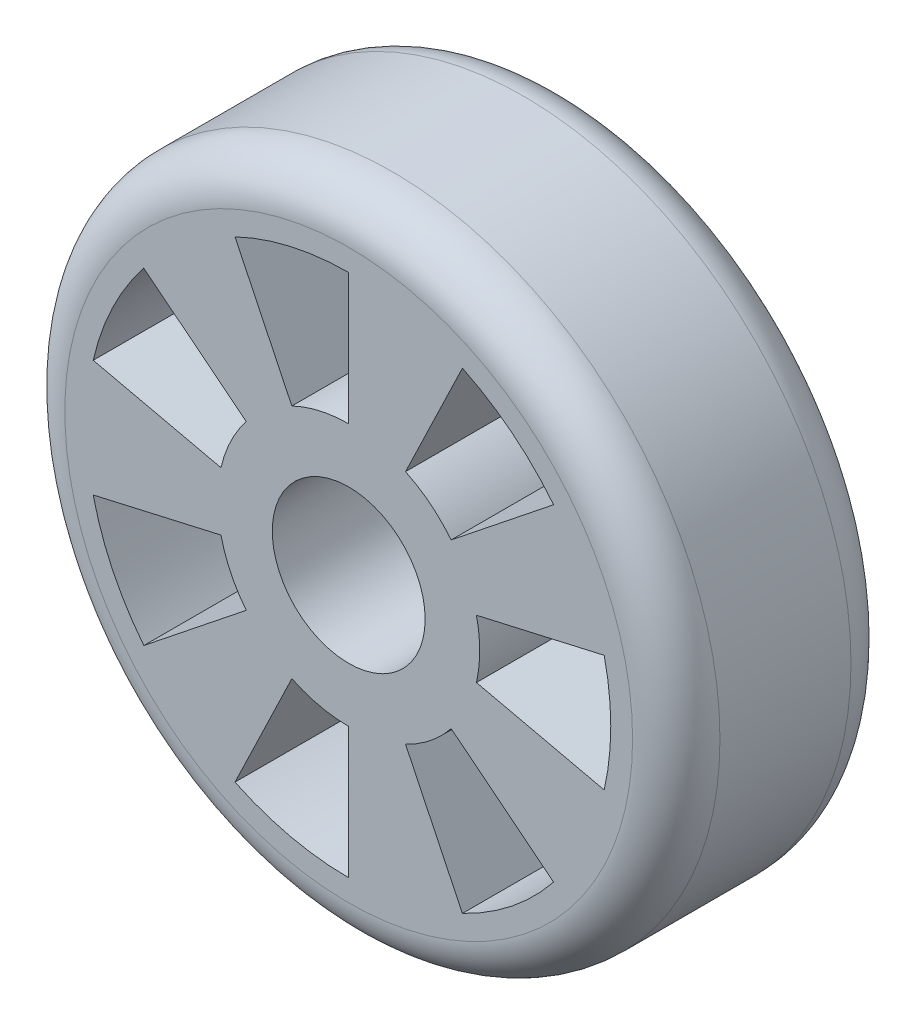
from build123d import *

# Parameters (mm, degrees)
SKETCH1_R           = 75
BOSS_EXTRUDE1_DEPTH = 50
FILLET1_R           = 10
SKETCH4_R           = 17.5
CUT_EXTRUDE1_DEPTH  = 51.0000001


with BuildPart() as part:
    # Sketch1 → Boss-Extrude1 (new body)
    with BuildSketch(Plane.XY):
        Circle(SKETCH1_R)
        with BuildLine():
            Line((0, 30), (0, 60))
            ThreePointArc((0, 60), (-13.351256037, 58.495674731), (-26.033024347, 54.058132074))
            Line((-26.033024347, 54.058132074), (-13.016512174, 27.029066037))
            ThreePointArc((-13.016512174, 27.029066037), (-6.675628019, 29.247837365), (0, 30))
        make_face(mode=Mode.SUBTRACT)
        with BuildLine():
            Line((13.016512174, 27.029066037), (26.033024347, 54.058132074))
            ThreePointArc((26.033024347, 54.058132074), (37.409388112, 46.909888948), (46.909888948, 37.409388112))
            Line((46.909888948, 37.409388112), (23.454944474, 18.704694056))
            ThreePointArc((23.454944474, 18.704694056), (18.704694056, 23.454944474), (13.016512174, 27.029066037))
        make_face(mode=Mode.SUBTRACT)
        with BuildLine():
            Line((29.247837365, 6.675628019), (58.495674731, 13.351256037))
            ThreePointArc((58.495674731, 13.351256037), (60, 0), (58.495674731, -13.351256037))
            Line((58.495674731, -13.351256037), (29.247837365, -6.675628019))
            ThreePointArc((29.247837365, -6.675628019), (30, 0), (29.247837365, 6.675628019))
        make_face(mode=Mode.SUBTRACT)
        with BuildLine():
            Line((23.454944474, -18.704694056), (46.909888948, -37.409388112))
            ThreePointArc((46.909888948, -37.409388112), (37.409388112, -46.909888948), (26.033024347, -54.058132074))
            Line((26.033024347, -54.058132074), (13.016512174, -27.029066037))
            ThreePointArc((13.016512174, -27.029066037), (18.704694056, -23.454944474), (23.454944474, -18.704694056))
        make_face(mode=Mode.SUBTRACT)
        with BuildLine():
            Line((0, -30), (0, -60))
            ThreePointArc((0, -60), (-13.351256037, -58.495674731), (-26.033024347, -54.058132074))
            Line((-26.033024347, -54.058132074), (-13.016512174, -27.029066037))
            ThreePointArc((-13.016512174, -27.029066037), (-6.675628019, -29.247837365), (0, -30))
        make_face(mode=Mode.SUBTRACT)
        with BuildLine():
            Line((-23.454944474, -18.704694056), (-46.909888948, -37.409388112))
            ThreePointArc((-46.909888948, -37.409388112), (-54.058132074, -26.033024347), (-58.495674731, -13.351256037))
            Line((-58.495674731, -13.351256037), (-29.247837365, -6.675628019))
            ThreePointArc((-29.247837365, -6.675628019), (-27.029066037, -13.016512174), (-23.454944474, -18.704694056))
        make_face(mode=Mode.SUBTRACT)
        with BuildLine():
            Line((-29.247837365, 6.675628019), (-58.495674731, 13.351256037))
            ThreePointArc((-58.495674731, 13.351256037), (-54.058132074, 26.033024347), (-46.909888948, 37.409388112))
            Line((-46.909888948, 37.409388112), (-23.454944474, 18.704694056))
            ThreePointArc((-23.454944474, 18.704694056), (-27.029066037, 13.016512174), (-29.247837365, 6.675628019))
        make_face(mode=Mode.SUBTRACT)
    extrude(amount=-BOSS_EXTRUDE1_DEPTH)

    # Fillet1
    fillet1_edges = [part.edges().sort_by_distance(p)[0] for p in [
        (-75, 0, 0),
        (-75, 0, -50),
    ]]
    fillet(fillet1_edges, radius=FILLET1_R)

    # Sketch4 → Cut-Extrude1 (cut, through all)
    with BuildSketch(Plane.XY):
        Circle(SKETCH4_R)
    extrude(amount=-CUT_EXTRUDE1_DEPTH, mode=Mode.SUBTRACT)


solid = part.part
